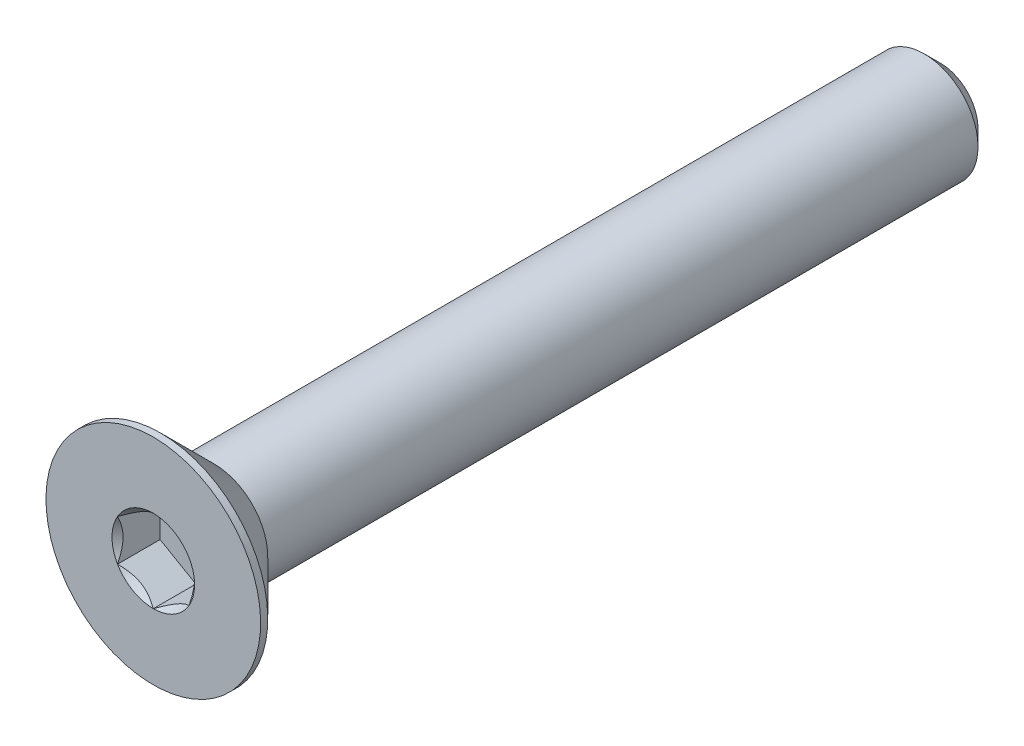
from build123d import *

# Parameters (mm, degrees)
SKETCH3_W          = 22
SKETCH3_H          = 1.5
CHAMFER1_SIZE      = 0.45
CUT_EXTRUDE1_DEPTH = 1.19


with BuildPart() as part:
    # Sketch3 → Revolve1 (revolve)
    with BuildSketch(Plane(origin=(0, 0, 0), x_dir=(0, 0, -1), z_dir=(1, 0, 0))):
        with Locations((0, 0.75)):
            Rectangle(SKETCH3_W, SKETCH3_H)
    revolve(axis=Axis((0, 0, -11), (0, 0, 1)))

    # Chamfer1
    chamfer1_edges = [part.edges().sort_by_distance(p)[0] for p in [
        (0, -1.5, -11),
    ]]
    chamfer(chamfer1_edges, length=CHAMFER1_SIZE)

    # Sketch6 → Revolve2 (revolve)
    with BuildSketch(Plane(origin=(0, 0, 0), x_dir=(0, 0, -1), z_dir=(1, 0, 0))):
        Polygon((-11, 3), (-10.8, 3), (-9.3, 1.5), (-9.3, 0), (-11, 0), align=None)
    revolve(axis=Axis((0, 0, -11), (0, 0, 1)))

    # Sketch8 → Cut-Extrude1 (cut)
    with BuildSketch(Plane.XY.offset(11)):
        Polygon((0, 1.154700538), (-1, 0.577350269), (-1, -0.577350269), (0, -1.154700538), (1, -0.577350269), (1, 0.577350269), align=None)
    extrude(amount=-CUT_EXTRUDE1_DEPTH, mode=Mode.SUBTRACT)

    # Cut-Extrude2 cone 1 section (through the dimple's axis) → Cut-Extrude2 (revolve, cut)
    with BuildSketch(Plane(origin=(0, 0, 11), x_dir=(0, -1, 0), z_dir=(1, 0, 0))):
        Polygon((0, 0), (1.154700538, 0), (0, 1.154700538), align=None)
    revolve(axis=Axis((0, 0, 11), (0, 0, -1)), mode=Mode.SUBTRACT)


solid = part.part
